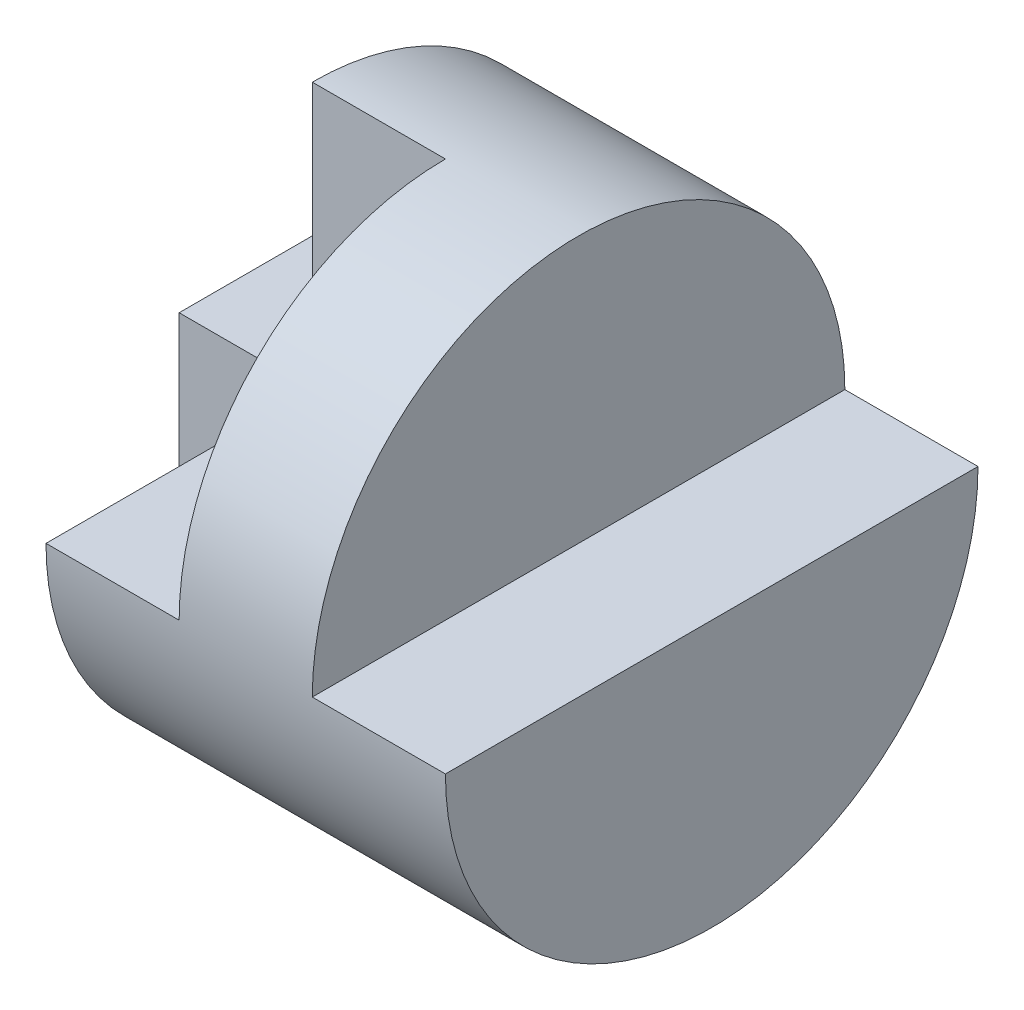
from build123d import *

# Parameters (mm, degrees)
SKETCH1_W           = 40
SKETCH1_H           = 40
BOSS_EXTRUDE1_DEPTH = 40
SKETCH2_W           = 10
SKETCH2_H           = 20
CUT_EXTRUDE1_DEPTH  = 40
CUT_EXTRUDE2_DEPTH  = 40
CUT_EXTRUDE3_DEPTH  = 40
CUT_EXTRUDE4_DEPTH  = 10
CUT_EXTRUDE5_DEPTH  = 10


with BuildPart() as part:
    # Sketch1 → Boss-Extrude1 (new body)
    with BuildSketch(Plane.XY):
        with Locations((20, 20)):
            Rectangle(SKETCH1_W, SKETCH1_H)
    extrude(amount=BOSS_EXTRUDE1_DEPTH)

    # Sketch2 → Cut-Extrude1 (cut)
    with BuildSketch(Plane.XY.offset(40)):
        with Locations((5, 30)):
            Rectangle(SKETCH2_W, SKETCH2_H)
        with Locations((35, 30)):
            Rectangle(SKETCH2_W, SKETCH2_H)
    extrude(amount=-CUT_EXTRUDE1_DEPTH, mode=Mode.SUBTRACT)

    # Sketch3 → Cut-Extrude2 (cut)
    with BuildSketch(Plane.ZY):
        with BuildLine():
            ThreePointArc((20, 0), (5.857864376, 5.857864376), (0, 20))
            Line((0, 20), (0, 0))
            Line((0, 0), (20, 0))
        make_face()
        with BuildLine():
            ThreePointArc((40, 20), (34.142135624, 5.857864376), (20, 0))
            Line((20, 0), (40, 0))
            Line((40, 0), (40, 20))
        make_face()
    extrude(amount=-CUT_EXTRUDE2_DEPTH, mode=Mode.SUBTRACT)

    # Sketch4 → Cut-Extrude3 (cut)
    with BuildSketch(Plane.ZY.offset(-10)):
        with BuildLine():
            Line((0, 40), (0, 20))
            ThreePointArc((0, 20), (5.857864376, 34.142135624), (20, 40))
            Line((20, 40), (0, 40))
        make_face()
        with BuildLine():
            Line((40, 40), (20, 40))
            ThreePointArc((20, 40), (34.142135624, 34.142135624), (40, 20))
            Line((40, 20), (40, 40))
        make_face()
    extrude(amount=-CUT_EXTRUDE3_DEPTH, mode=Mode.SUBTRACT)

    # Sketch5 → Cut-Extrude4 (cut)
    with BuildSketch(Plane.ZY):
        with BuildLine():
            Line((20, 0), (20, 20))
            Line((20, 20), (40, 20))
            ThreePointArc((40, 20), (34.142135624, 5.857864376), (20, 0))
        make_face()
    extrude(amount=-CUT_EXTRUDE4_DEPTH, mode=Mode.SUBTRACT)

    # Sketch6 → Cut-Extrude5 (cut)
    with BuildSketch(Plane.ZY.offset(-10)):
        with BuildLine():
            Line((20, 40), (20, 20))
            Line((20, 20), (40, 20))
            ThreePointArc((40, 20), (34.142135624, 34.142135624), (20, 40))
        make_face()
    extrude(amount=-CUT_EXTRUDE5_DEPTH, mode=Mode.SUBTRACT)


solid = part.part
